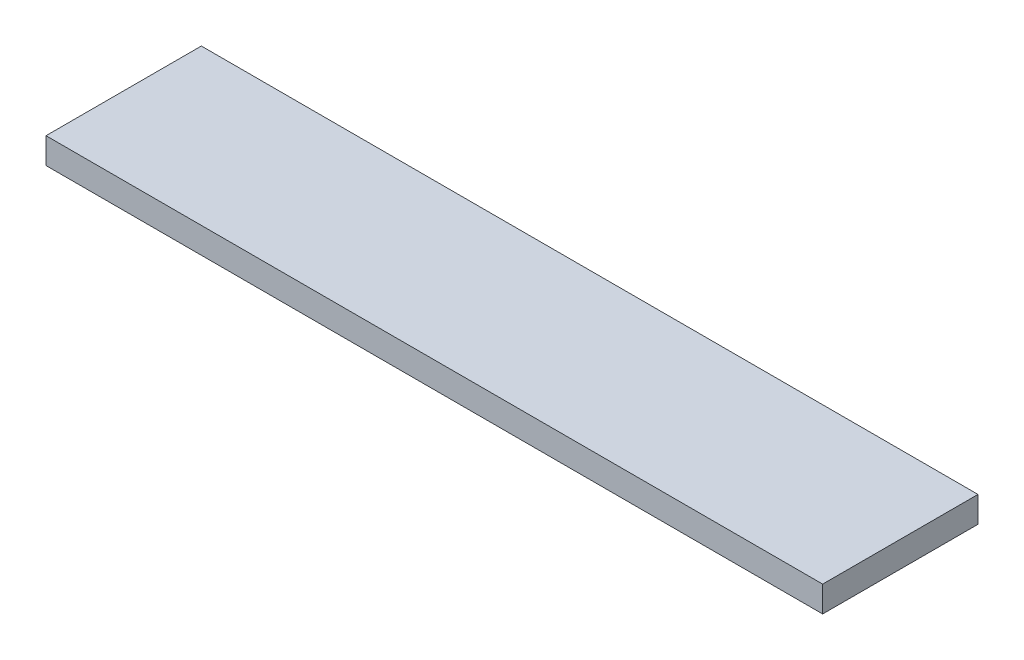
from build123d import *

# Parameters (mm, degrees)
SKETCH1_W           = 190.5
SKETCH1_H           = 38.1
BOSS_EXTRUDE1_DEPTH = 6.35


with BuildPart() as part:
    # Sketch1 → Boss-Extrude1 (new body)
    with BuildSketch(Plane(origin=(0, 0, 0), x_dir=(1, 0, 0), z_dir=(0, 1, 0))):
        Rectangle(SKETCH1_W, SKETCH1_H)
    extrude(amount=BOSS_EXTRUDE1_DEPTH)


solid = part.part
